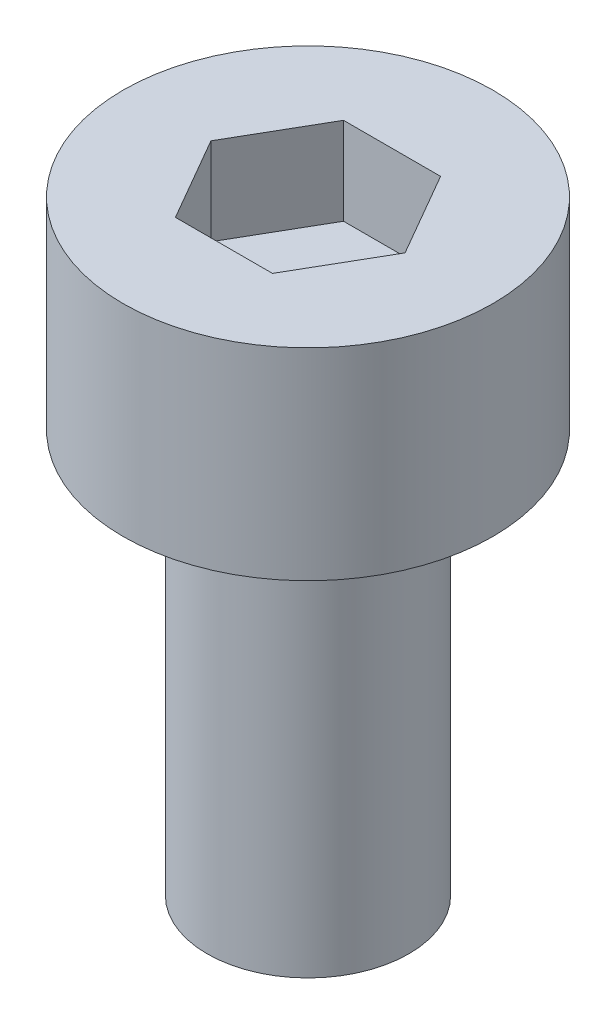
from build123d import *

# Parameters (mm, degrees)
SKETCH_1_R            = 2.75
EXTRUDE_248_DEPTH     = 3
CUT_EXTRUDE_378_DEPTH = 1.3
SKETCH_3_R            = 1.5
EXTRUDE_479_DEPTH     = 6


with BuildPart() as part:
    # 草图1 → Extrude 248 (new body)
    with BuildSketch(Plane(origin=(0, 0, 0), x_dir=(1, 0, 0), z_dir=(0, 1, 0))):
        Circle(SKETCH_1_R)
    extrude(amount=EXTRUDE_248_DEPTH)

    # 草图2 → Cut-Extrude 378 (cut)
    with BuildSketch(Plane(origin=(0, 3, 0), x_dir=(1, 0, 0), z_dir=(0, 1, 0))):
        Polygon((1.443375673, 0), (0.721687836, 1.25), (-0.721687836, 1.25), (-1.443375673, 0), (-0.721687836, -1.25), (0.721687836, -1.25), align=None)
    extrude(amount=-CUT_EXTRUDE_378_DEPTH, mode=Mode.SUBTRACT)

    # 草图3 → Extrude 479 (add)
    with BuildSketch(Plane.XZ):
        Circle(SKETCH_3_R)
    extrude(amount=EXTRUDE_479_DEPTH)


solid = part.part
